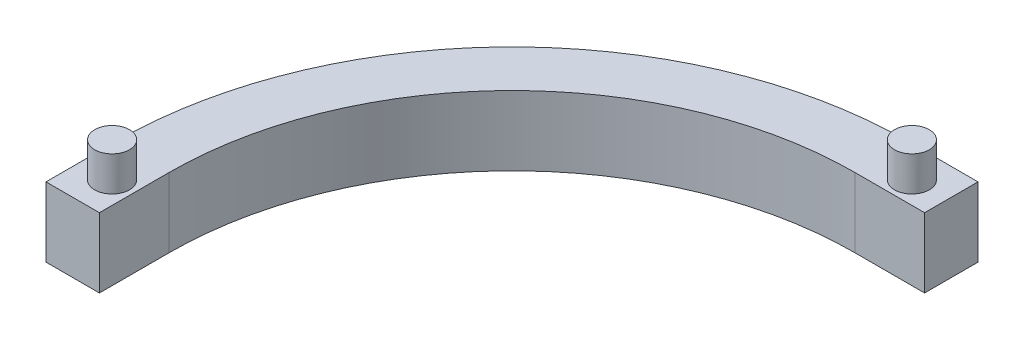
from build123d import *

# Parameters (mm, degrees)
BOSS_EXTRUDE1_DEPTH    = 10
SKETCH2_R              = 3
CUT_EXTRUDE1_DEPTH     = 6
SKETCH3_R              = 2.5
BOSS_EXTRUDE2_DEPTH    = 5
SPLIT1_SURFACE_1_BACK  = 134.079
SPLIT1_SURFACE_1_DEPTH = 268.158
SKETCH5_W              = 9.5
SKETCH5_H              = 10
BOSS_EXTRUDE3_DEPTH    = 10
SKETCH6_R              = 2.5
BOSS_EXTRUDE4_DEPTH    = 5
SKETCH7_R              = 3
CUT_EXTRUDE2_DEPTH     = 5
SPLIT3_SURFACE_2_BACK  = 96.932
SPLIT3_SURFACE_2_DEPTH = 193.864


with BuildPart() as part:
    # Sketch1 → Boss-Extrude1 (new body)
    with BuildSketch(Plane(origin=(0, 0, 0), x_dir=(1, 0, 0), z_dir=(0, 1, 0))):
        with BuildLine():
            Line((-57, 0), (-57, -10))
            Line((-57, -10), (-47.5, -10))
            Line((-47.5, -10), (-47.5, 0))
            ThreePointArc((-47.5, 0), (0, 47.5), (47.5, 0))
            Line((47.5, 0), (47.5, -10))
            Line((47.5, -10), (57, -10))
            Line((57, -10), (57, 0))
            ThreePointArc((57, 0), (0, 57), (-57, 0))
        make_face()
    extrude(amount=BOSS_EXTRUDE1_DEPTH)

    # Sketch2 → Cut-Extrude1 (cut)
    with BuildSketch(Plane.XZ):
        with Locations(Location((-52.5, 5, 0), (0, 0, 270))):
            Circle(SKETCH2_R)
    cut_extrude1 = extrude(amount=-CUT_EXTRUDE1_DEPTH, mode=Mode.SUBTRACT)

    # Sketch3 → Boss-Extrude2 (add)
    with BuildSketch(Plane(origin=(0, 10, 0), x_dir=(1, 0, 0), z_dir=(0, 1, 0))):
        with Locations(Location((-52.5, -5, 0), (0, 0, 90))):
            Circle(SKETCH3_R)
    boss_extrude2 = extrude(amount=BOSS_EXTRUDE2_DEPTH)

    # Mirror1: Cut-Extrude1, Boss-Extrude2 across plane
    add(cut_extrude1.mirror(Plane.ZY), mode=Mode.SUBTRACT)
    add(boss_extrude2.mirror(Plane.ZY))

    # Split1: cut with a surface, the side it looks to stays
    # Split1 surface: a surface, the sketch's curves swept straight by 268.158 mm
    with BuildLine(Plane(origin=(0, 10, 0), x_dir=(1, 0, 0), z_dir=(0, 1, 0)).offset(-SPLIT1_SURFACE_1_BACK), mode=Mode.PRIVATE) as split1_surface_1_path:
        Line((0, 47.5), (0, 57))
    split1_surface_1 = Shell.extrude(split1_surface_1_path.wire(), (0 * SPLIT1_SURFACE_1_DEPTH, 1 * SPLIT1_SURFACE_1_DEPTH, 0 * SPLIT1_SURFACE_1_DEPTH))
    split(bisect_by=split1_surface_1, keep=Keep.TOP)

    # Sketch5 → Boss-Extrude3 (add)
    with BuildSketch(Plane(origin=(0, 0, 0), x_dir=(0, 0, -1), z_dir=(1, 0, 0))):
        with Locations((52.25, 5)):
            Rectangle(SKETCH5_W, SKETCH5_H)
    extrude(amount=BOSS_EXTRUDE3_DEPTH)

    # Sketch6 → Boss-Extrude4 (add)
    with BuildSketch(Plane(origin=(0, 10, 0), x_dir=(1, 0, 0), z_dir=(0, 1, 0))):
        with Locations(Location((5, 52.5, 0), (0, 0, 90))):
            Circle(SKETCH6_R)
    extrude(amount=BOSS_EXTRUDE4_DEPTH)

    # Sketch7 → Cut-Extrude2 (cut)
    with BuildSketch(Plane.XZ):
        with Locations(Location((5, -52.5, 0), (0, 0, 270))):
            Circle(SKETCH7_R)
    extrude(amount=-CUT_EXTRUDE2_DEPTH, mode=Mode.SUBTRACT)

    # Split3: cut with a surface, the side it looks to stays
    # Split3 surface: a surface, the sketch's curves swept straight by 193.864 mm
    with BuildLine(Plane(origin=(0, 10, 0), x_dir=(1, 0, 0), z_dir=(0, 1, 0)).offset(-SPLIT3_SURFACE_2_BACK), mode=Mode.PRIVATE) as split3_surface_2_path:
        Line((-49.32, -10), (-49.32, 0))
        ThreePointArc((-49.32, 0), (-34.874506448, 34.874506448), (0, 49.32))
        Line((0, 49.32), (10, 49.32))
    split3_surface_2 = Shell.extrude(split3_surface_2_path.wire(), (0 * SPLIT3_SURFACE_2_DEPTH, 1 * SPLIT3_SURFACE_2_DEPTH, 0 * SPLIT3_SURFACE_2_DEPTH))
    split(bisect_by=split3_surface_2, keep=Keep.TOP)


solid = part.part
